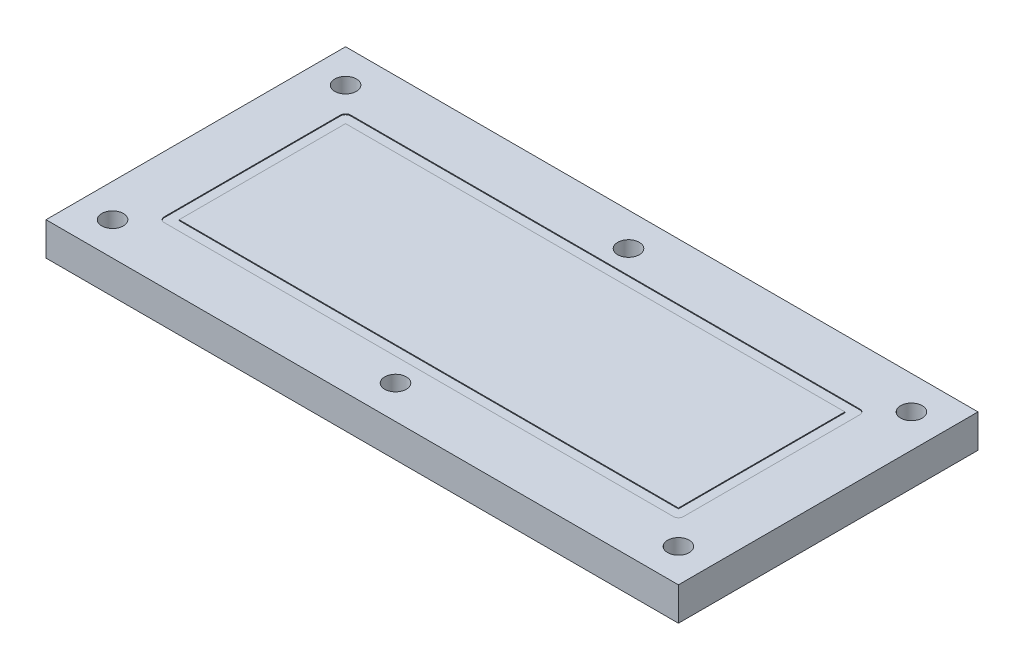
from build123d import *

# Parameters (mm, degrees)
SKETCH1_W           = 380
SKETCH1_H           = 180
BOSS_EXTRUDE1_DEPTH = 20
SKETCH2_R           = 6.5
CUT_EXTRUDE1_DEPTH  = 21
SKETCH3_W           = 300
SKETCH3_H           = 100
CUT_EXTRUDE2_DEPTH  = 0.5


with BuildPart() as part:
    # Sketch1 → Boss-Extrude1 (new body)
    with BuildSketch(Plane(origin=(0, 0, 0), x_dir=(1, 0, 0), z_dir=(0, 1, 0))):
        Rectangle(SKETCH1_W, SKETCH1_H)
    extrude(amount=BOSS_EXTRUDE1_DEPTH)

    # Sketch2 → Cut-Extrude1 (cut, through all)
    with BuildSketch(Plane(origin=(0, 20, 0), x_dir=(1, 0, 0), z_dir=(0, 1, 0))):
        with Locations((-170, 70)):
            Circle(SKETCH2_R)
        with Locations((-170, -70)):
            Circle(SKETCH2_R)
        with Locations((0, -70)):
            Circle(SKETCH2_R)
        with Locations((0, 70)):
            Circle(SKETCH2_R)
        with Locations((170, -70)):
            Circle(SKETCH2_R)
        with Locations((170, 70)):
            Circle(SKETCH2_R)
    extrude(amount=-CUT_EXTRUDE1_DEPTH, mode=Mode.SUBTRACT)

    # Sketch3 → Cut-Extrude2 (cut)
    with BuildSketch(Plane(origin=(0, 20, 0), x_dir=(1, 0, 0), z_dir=(0, 1, 0))):
        with BuildLine():
            Line((-153, -56), (153, -56))
            ThreePointArc((153, -56), (155.121320344, -55.121320344), (156, -53))
            Line((156, -53), (156, 53))
            ThreePointArc((156, 53), (155.121320344, 55.121320344), (153, 56))
            Line((153, 56), (-153, 56))
            ThreePointArc((-153, 56), (-155.121320344, 55.121320344), (-156, 53))
            Line((-156, 53), (-156, -53))
            ThreePointArc((-156, -53), (-155.121320344, -55.121320344), (-153, -56))
        make_face()
        Rectangle(SKETCH3_W, SKETCH3_H, mode=Mode.SUBTRACT)
    extrude(amount=-CUT_EXTRUDE2_DEPTH, mode=Mode.SUBTRACT)


solid = part.part
